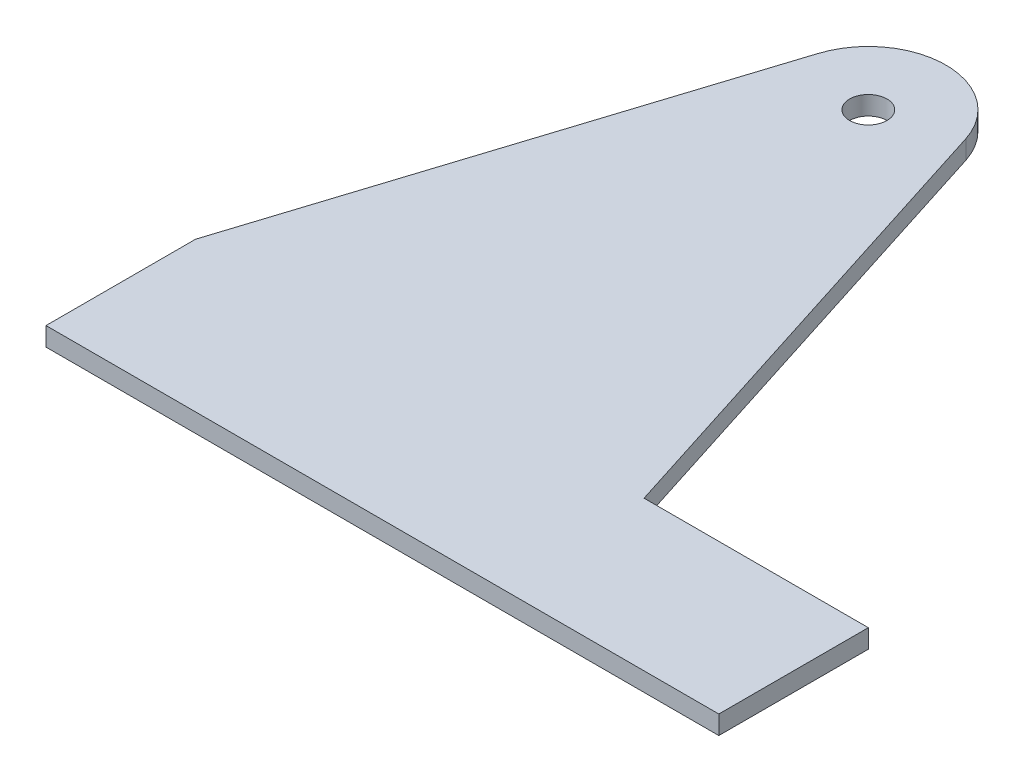
from build123d import *

# Parameters (mm, degrees)
SKETCH1_R           = 6.35
BOSS_EXTRUDE1_DEPTH = 6.35


with BuildPart() as part:
    # Sketch1 → Boss-Extrude1 (new body)
    with BuildSketch(Plane(origin=(0, 0, 0), x_dir=(1, 0, 0), z_dir=(0, 1, 0))):
        with BuildLine():
            Line((76.2, -152.4), (25.106996492, 7.99757633))
            ThreePointArc((25.106996492, 7.99757633), (0, 26.35), (-25.106996492, 7.99757633))
            Line((-25.106996492, 7.99757633), (-76.2, -152.4))
            Line((-76.2, -152.4), (-76.2, -203.2))
            Line((-76.2, -203.2), (152.4, -203.2))
            Line((152.4, -203.2), (152.4, -152.4))
            Line((152.4, -152.4), (76.2, -152.4))
        make_face()
        Circle(SKETCH1_R, mode=Mode.SUBTRACT)
    extrude(amount=BOSS_EXTRUDE1_DEPTH)


solid = part.part
